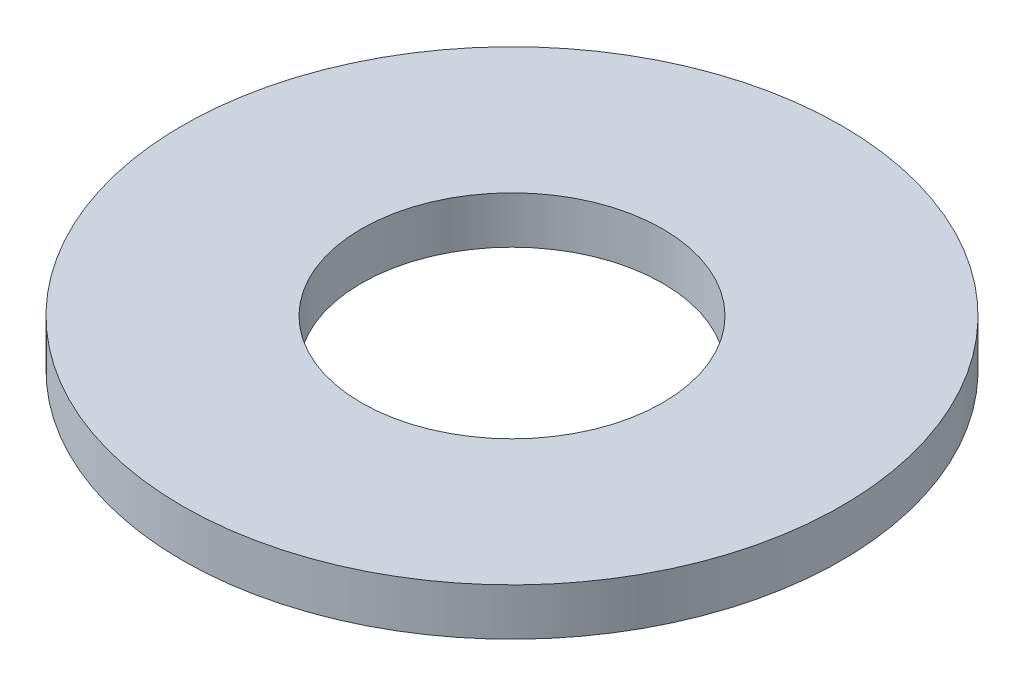
from build123d import *

# Parameters (mm, degrees)
SKETCH1_R      = 3.5
SKETCH1_R_2    = 1.6
EXTRUDE1_DEPTH = 0.5


with BuildPart() as part:
    # Sketch1 → Extrude1 (new body)
    with BuildSketch(Plane(origin=(0, 0, 0), x_dir=(1, 0, 0), z_dir=(0, 1, 0))):
        with Locations(Location((0, 0, 0), (0, 0, 270))):  # turned: the seam where the file's is
            Circle(SKETCH1_R)
        with Locations(Location((0, 0, 0), (0, 0, 270))):  # turned: the seam where the file's is
            Circle(SKETCH1_R_2, mode=Mode.SUBTRACT)
    extrude(amount=EXTRUDE1_DEPTH)


solid = part.part
